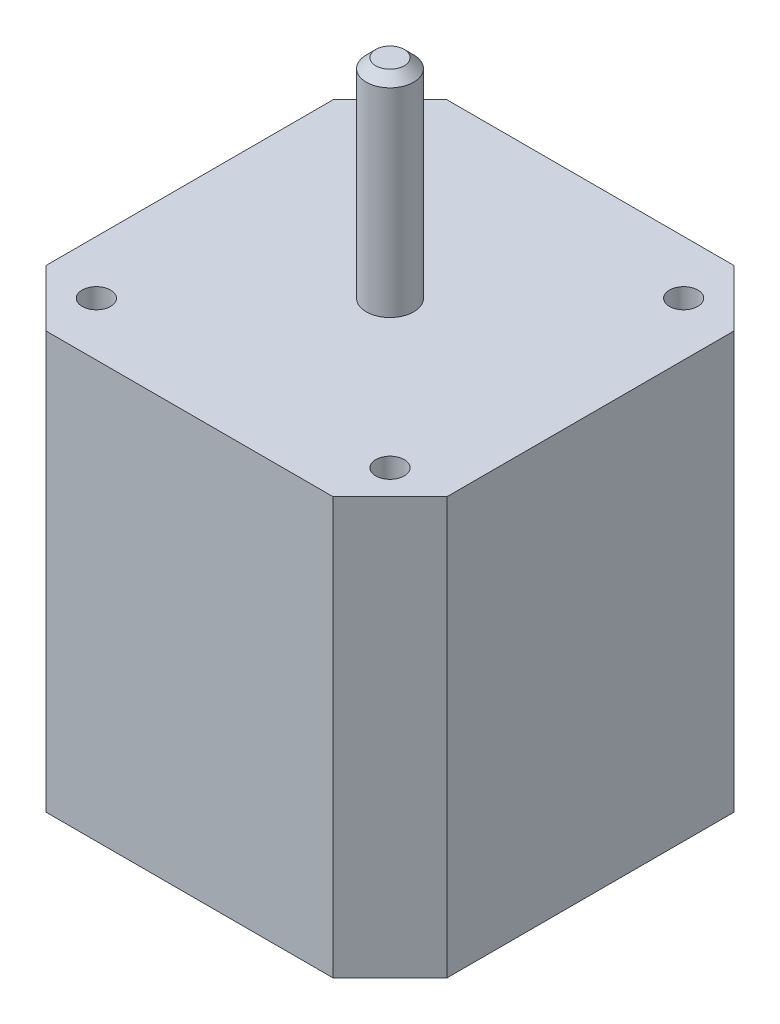
from build123d import *

# Parameters (mm, degrees)
SKETCH1_W           = 42.3
SKETCH1_H           = 42.3
SKETCH1_R           = 2.5
BOSS_EXTRUDE1_DEPTH = 44
SKETCH1_3_R         = 2.5
BOSS_EXTRUDE2_DEPTH = 66
CHAMFER1_SIZE       = 6
CHAMFER2_SIZE       = 1
SKETCH2_R           = 1.5
CUT_EXTRUDE1_DEPTH  = 10


with BuildPart() as part:
    # Sketch1 → Boss-Extrude1 (new body)
    with BuildSketch(Plane(origin=(0, 0, 0), x_dir=(1, 0, 0), z_dir=(0, 1, 0))):
        Rectangle(SKETCH1_W, SKETCH1_H)
        Circle(SKETCH1_R, mode=Mode.SUBTRACT)
        Circle(SKETCH1_R)
    extrude(amount=BOSS_EXTRUDE1_DEPTH)

    # Sketch1_3 → Boss-Extrude2 (add)
    with BuildSketch(Plane(origin=(0, 0, 0), x_dir=(1, 0, 0), z_dir=(0, 1, 0))):
        with Locations(Location((0, 0, 0), (0, 0, 270))):  # turned: the seam where the file's is
            Circle(SKETCH1_3_R)
    extrude(amount=BOSS_EXTRUDE2_DEPTH)

    # Chamfer1
    chamfer1_edges = [part.edges().sort_by_distance(p)[0] for p in [
        (21.15, 22, 21.15),
        (-21.15, 22, 21.15),
        (-21.15, 22, -21.15),
        (21.15, 22, -21.15),
    ]]
    chamfer(chamfer1_edges, length=CHAMFER1_SIZE)

    # Chamfer2
    chamfer2_edges = [part.edges().sort_by_distance(p)[0] for p in [
        (0, 66, -2.5),
    ]]
    chamfer(chamfer2_edges, length=CHAMFER2_SIZE)

    # Sketch2 → Cut-Extrude1 (cut)
    with BuildSketch(Plane(origin=(0, 44, 0), x_dir=(1, 0, 0), z_dir=(0, 1, 0))):
        with Locations(Location((-15.5, 15.5, 0), (0, 0, 270))):  # turned: the seam where the file's is
            Circle(SKETCH2_R)
        with Locations(Location((15.5, 15.5, 0), (0, 0, 270))):  # turned: the seam where the file's is
            Circle(SKETCH2_R)
        with Locations(Location((15.5, -15.5, 0), (0, 0, 270))):  # turned: the seam where the file's is
            Circle(SKETCH2_R)
        with Locations(Location((-15.5, -15.5, 0), (0, 0, 270))):  # turned: the seam where the file's is
            Circle(SKETCH2_R)
    extrude(amount=-CUT_EXTRUDE1_DEPTH, mode=Mode.SUBTRACT)


solid = part.part
